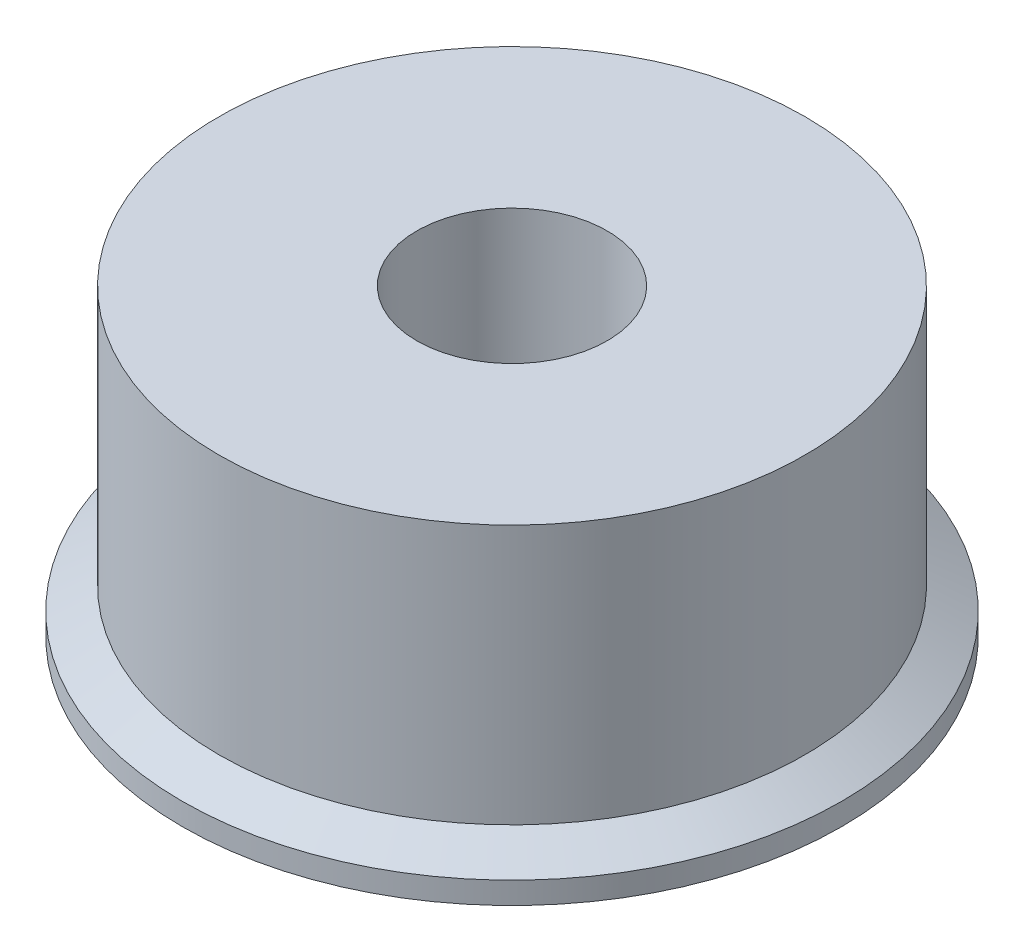
from build123d import *


with BuildPart() as part:
    # Sketch1 → Revolve1 (revolve)
    with BuildSketch(Plane.XY):
        Polygon((-3.302, 10.524), (-10.16, 10.524), (-10.16, 1.524), (-11.43, 0.762), (-11.43, 0), (-7.9375, 0), (-7.9375, 5.08), (-3.302, 5.08), align=None)
    revolve(axis=Axis((0, 7.62, 0), (0, -1, 0)))


solid = part.part
